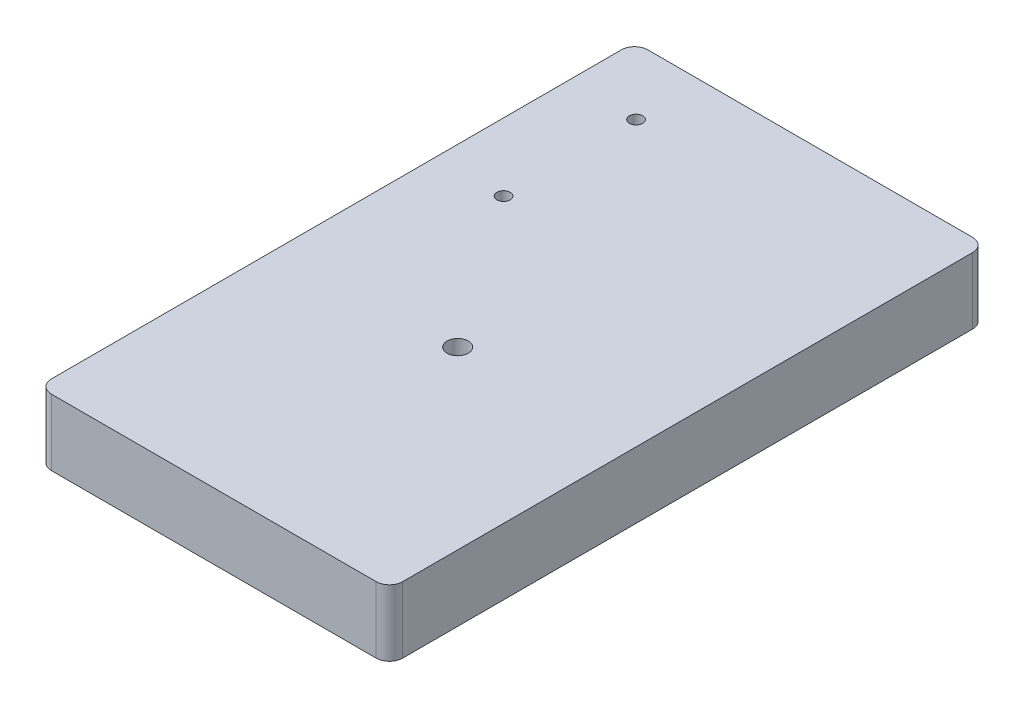
from build123d import *

# Parameters (mm, degrees)
ESQUISSE1_R             = 1.6
EXTRUSION1_DEPTH        = 10
ESQUISSE2_R             = 1.1
ENL_V_MAT_EXTRU_1_DEPTH = 4
ESQUISSE4_R             = 1
ENL_V_MAT_EXTRU_2_DEPTH = 11


with BuildPart() as part:
    # Esquisse1 → Extrusion1 (new body)
    with BuildSketch(Plane(origin=(0, 0, 0), x_dir=(1, 0, 0), z_dir=(0, 1, 0))):
        with BuildLine():
            Line((0, 88), (0, 2))
            ThreePointArc((0, 2), (0.585786438, 0.585786438), (2, 0))
            Line((2, 0), (51, 0))
            ThreePointArc((51, 0), (52.414213562, 0.585786438), (53, 2))
            Line((53, 2), (53, 88))
            ThreePointArc((53, 88), (52.414213562, 89.414213562), (51, 90))
            Line((51, 90), (2, 90))
            ThreePointArc((2, 90), (0.585786438, 89.414213562), (0, 88))
        make_face()
        with Locations(Location((26.5, 36.8, 0), (0, 0, 270))):  # turned: the seam where the file's is
            Circle(ESQUISSE1_R, mode=Mode.SUBTRACT)
    extrude(amount=EXTRUSION1_DEPTH)

    # Esquisse2 → Enlèv. mat.-Extru.1 (cut)
    with BuildSketch(Plane.XZ):
        with Locations(Location((45, -23, 0), (0, 0, 270))):  # turned: the seam where the file's is
            Circle(ESQUISSE2_R)
        with Locations(Location((45, -7, 0), (0, 0, 270))):  # turned: the seam where the file's is
            Circle(ESQUISSE2_R)
        with BuildLine():
            Line((41, -82.7372583), (41, -81.2627417))
            ThreePointArc((41, -81.2627417), (41, -79), (38.7372583, -79))
            Line((38.7372583, -79), (27.2627417, -79))
            ThreePointArc((27.2627417, -79), (25, -79), (25, -81.2627417))
            Line((25, -81.2627417), (25, -82.7372583))
            ThreePointArc((25, -82.7372583), (25, -85), (27.2627417, -85))
            Line((27.2627417, -85), (38.7372583, -85))
            ThreePointArc((38.7372583, -85), (41, -85), (41, -82.7372583))
        make_face()
        with BuildLine():
            Line((45.7372583, -49.5), (44.2627417, -49.5))
            ThreePointArc((44.2627417, -49.5), (42, -49.5), (42, -51.7627417))
            Line((42, -51.7627417), (42, -67.2372583))
            ThreePointArc((42, -67.2372583), (42, -69.5), (44.2627417, -69.5))
            Line((44.2627417, -69.5), (45.7372583, -69.5))
            ThreePointArc((45.7372583, -69.5), (48, -69.5), (48, -67.2372583))
            Line((48, -67.2372583), (48, -51.7627417))
            ThreePointArc((48, -51.7627417), (48, -49.5), (45.7372583, -49.5))
        make_face()
        with BuildLine():
            Line((24, -67.2372583), (24, -51.7627417))
            ThreePointArc((24, -51.7627417), (24, -49.5), (21.7372583, -49.5))
            Line((21.7372583, -49.5), (20.2627417, -49.5))
            ThreePointArc((20.2627417, -49.5), (18, -49.5), (18, -51.7627417))
            Line((18, -51.7627417), (18, -67.2372583))
            ThreePointArc((18, -67.2372583), (18, -69.5), (20.2627417, -69.5))
            Line((20.2627417, -69.5), (21.7372583, -69.5))
            ThreePointArc((21.7372583, -69.5), (24, -69.5), (24, -67.2372583))
        make_face()
    extrude(amount=-ENL_V_MAT_EXTRU_1_DEPTH, mode=Mode.SUBTRACT)

    # Esquisse4 → Enlèv. mat.-Extru.2 (cut, through all)
    with BuildSketch(Plane(origin=(0, 10, 0), x_dir=(1, 0, 0), z_dir=(0, 1, 0))):
        with Locations(Location((10.223320542, 80, 0), (0, 0, 270))):  # turned: the seam where the file's is
            Circle(ESQUISSE4_R)
        with Locations(Location((10.223320542, 60, 0), (0, 0, 270))):  # turned: the seam where the file's is
            Circle(ESQUISSE4_R)
    extrude(amount=-ENL_V_MAT_EXTRU_2_DEPTH, mode=Mode.SUBTRACT)


solid = part.part
